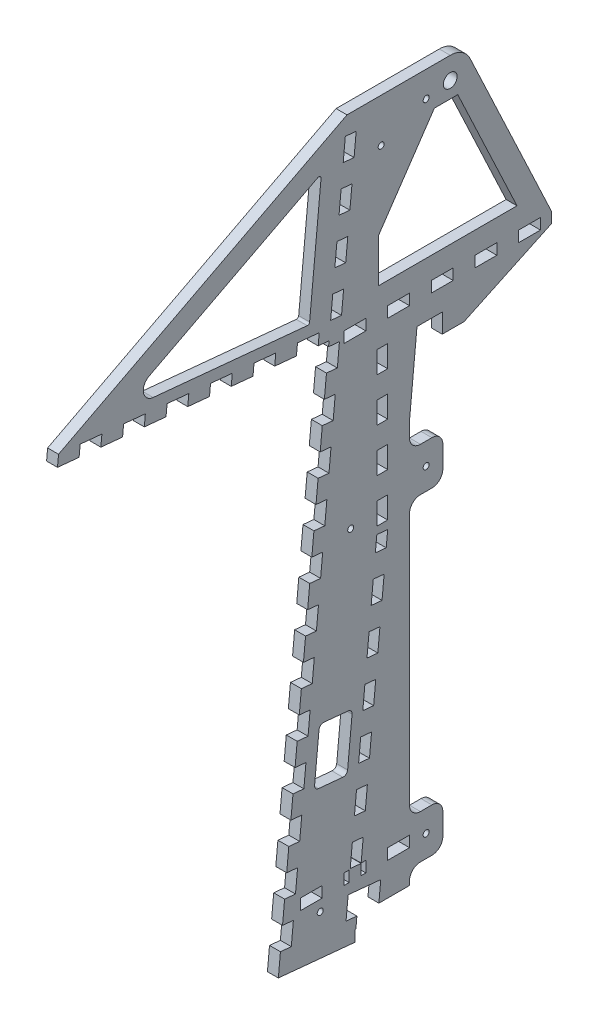
from build123d import *

# Parameters (mm, degrees)
BOSS_EXTRUDE1_DEPTH = 6.35
SKETCH2_W           = 19.05
SKETCH2_H           = 84.666666666
SKETCH2_H_2         = 84.666666667
CUT_EXTRUDE4_DEPTH  = 7.35
FILLET1_R           = 12.7
SKETCH3_R           = 4
CUT_EXTRUDE5_DEPTH  = 7.35
FILLET2_R           = 6.35
CUT_EXTRUDE6_DEPTH  = 7.35
CUT_EXTRUDE11_DEPTH = 7.35
LPATTERN1_COUNT     = 17
LPATTERN1_PITCH     = 25.4
CUT_EXTRUDE13_DEPTH = 7.35
LPATTERN2_COUNT     = 17
LPATTERN2_PITCH     = 25.4
SKETCH8_W           = 12.7
SKETCH8_H           = 6.35
CUT_EXTRUDE14_DEPTH = 7.35
LPATTERN3_COUNT     = 5
LPATTERN3_PITCH     = 25.4
SKETCH9_W           = 12.7
SKETCH9_H           = 6.35
CUT_EXTRUDE15_DEPTH = 7.35
LPATTERN4_COUNT     = 3
LPATTERN4_PITCH     = 25.4
CUT_EXTRUDE16_DEPTH = 7.35
LPATTERN5_COUNT     = 8
LPATTERN5_PITCH     = 25.4
BOSS_EXTRUDE2_DEPTH = 6.35
SKETCH13_W          = 12.7
SKETCH13_H          = 6.35
CUT_EXTRUDE17_DEPTH = 7.35
LPATTERN6_COUNT     = 3
LPATTERN6_PITCH     = 25.4
SKETCH15_W          = 2.976007875
SKETCH15_H          = 6.35
CUT_EXTRUDE20_DEPTH = 7.35
CUT_EXTRUDE21_DEPTH = 7.35
SKETCH17_W          = 6.35
SKETCH17_H          = 6.35
CUT_EXTRUDE22_DEPTH = 7.35
SKETCH18_W          = 6.35
SKETCH18_H          = 12.7
CUT_EXTRUDE23_DEPTH = 7.35
LPATTERN7_COUNT     = 4
LPATTERN7_PITCH     = 25.4
SKETCH19_R          = 1.75
CUT_EXTRUDE24_DEPTH = 7.35
SKETCH20_W          = 6.35
SKETCH20_H          = 6.35
BOSS_EXTRUDE3_DEPTH = 6.35
FILLET3_R           = 2.54
FILLET4_R           = 1.27
CUT_EXTRUDE27_DEPTH = 7.35
CUT_EXTRUDE28_DEPTH = 7.35
SKETCH23_W          = 50.8
SKETCH23_H          = 12.7
CUT_EXTRUDE29_DEPTH = 7.35
CUT_EXTRUDE30_DEPTH = 7.35
SKETCH25_R          = 1.75
CUT_EXTRUDE32_DEPTH = 7.35
SKETCH26_W          = 19.381019212
SKETCH26_H          = 25.4
SKETCH26_R          = 1.75
BOSS_EXTRUDE4_DEPTH = 6.35
FILLET5_R           = 6.35


with BuildPart() as part:
    # Sketch1 → Boss-Extrude1 (new body)
    with BuildSketch(Plane(origin=(0, 0, 0), x_dir=(0, 0, -1), z_dir=(1, 0, 0))):
        Polygon((-128.051747831, 325.716377135), (29.898471713, 310.507500832), (0.41022444, 4.2603437), (44.655585457, 0), (108.458541785, 0), (108.458541785, 280.894117647), (159.258541785, 304.8), (159.258541785, 311.15), (108.458541785, 419.1), (40.3547401, 419.1), (-127.443127302, 332.037142994), align=None)
    extrude(amount=BOSS_EXTRUDE1_DEPTH)

    # Sketch2 → Cut-Extrude4 (cut, through all)
    with BuildSketch(Plane(origin=(6.35, 0, 0), x_dir=(0, 0, -1), z_dir=(1, 0, 0))):
        Polygon((-93.813479632, 335.17834558), (25.474926883, 397.071798933), (18.474181051, 324.366273609), align=None)
        Polygon((91.177408074, 397.071798933), (84.126950747, 323.85), (139.246110214, 323.85), (104.788793069, 397.071798933), align=None)
        Polygon((81.069773467, 292.1), (76.708541785, 246.806877223), (76.708541785, 207.433333333), (95.758541785, 207.433333333), (95.758541785, 292.1), align=None)
        with Locations((86.233541785, 152.4)):
            Rectangle(SKETCH2_W, SKETCH2_H)
        with Locations((86.233541785, 55.033333334)):
            Rectangle(SKETCH2_W, SKETCH2_H_2)
    extrude(amount=-CUT_EXTRUDE4_DEPTH, mode=Mode.SUBTRACT)

    # Fillet1
    fillet1_edges = [part.edges().sort_by_distance(p)[0] for p in [
        (3.175, 419.1, -108.458541785),
    ]]
    fillet(fillet1_edges, radius=FILLET1_R)

    # Sketch3 → Cut-Extrude5 (cut, through all)
    with BuildSketch(Plane(origin=(6.35, 0, 0), x_dir=(0, 0, -1), z_dir=(1, 0, 0))):
        with Locations((100.399051391, 406.4)):
            Circle(SKETCH3_R)
    extrude(amount=-CUT_EXTRUDE5_DEPTH, mode=Mode.SUBTRACT)

    # Fillet2
    fillet2_edges = [part.edges().sort_by_distance(p)[0] for p in [
        (3.175, 335.17834558, 93.813479632),
    ]]
    fillet(fillet2_edges, radius=FILLET2_R)

    # Sketch4 → Cut-Extrude6 (cut, through all)
    with BuildSketch(Plane(origin=(6.35, 0, 0), x_dir=(0, 0, -1), z_dir=(1, 0, 0))):
        Polygon((21.256152575, 88.249017223), (24.323216655, 120.10169557), (43.534363284, 118.251872547), (40.467299203, 86.399194199), align=None)
    extrude(amount=-CUT_EXTRUDE6_DEPTH, mode=Mode.SUBTRACT)

    # Sketch5 → Cut-Extrude11 (cut, through all)
    with BuildSketch(Plane(origin=(6.35, 0, 0), x_dir=(0, 0, -1), z_dir=(1, 0, 0))):
        Polygon((1.627465497, 16.901875419), (2.844706554, 29.543407138), (9.165472413, 28.93478661), (7.948231356, 16.29325489), align=None)
    cut_extrude11 = extrude(amount=-CUT_EXTRUDE11_DEPTH, mode=Mode.SUBTRACT)

    # LPattern1: Cut-Extrude11 ×17
    with Locations(*[Vector(0, 0.995396198, -0.095845753) * (i * LPATTERN1_PITCH) for i in range(1, LPATTERN1_COUNT)]):
        add(cut_extrude11, mode=Mode.SUBTRACT)

    # Sketch7 → Cut-Extrude13 (cut, through all)
    with BuildSketch(Plane(origin=(6.35, 0, 0), x_dir=(0, 0, -1), z_dir=(1, 0, 0))):
        Polygon((23.577705854, 311.116121361), (10.936174134, 312.333362418), (11.544794663, 318.654128277), (24.186326382, 317.43688722), align=None)
    cut_extrude13 = extrude(amount=-CUT_EXTRUDE13_DEPTH, mode=Mode.SUBTRACT)

    # LPattern2: Cut-Extrude13 ×17
    with Locations(*[Vector(0, 0.095845753, 0.995396198) * (i * LPATTERN2_PITCH) for i in range(1, LPATTERN2_COUNT)]):
        add(cut_extrude13, mode=Mode.SUBTRACT)

    # Sketch8 → Cut-Extrude14 (cut, through all)
    with BuildSketch(Plane(origin=(6.35, 0, 0), x_dir=(0, 0, -1), z_dir=(1, 0, 0))):
        with Locations((146.558541785, 307.975)):
            Rectangle(SKETCH8_W, SKETCH8_H)
    cut_extrude14 = extrude(amount=-CUT_EXTRUDE14_DEPTH, mode=Mode.SUBTRACT)

    # LPattern3: Cut-Extrude14 ×5
    with Locations(*[(0, 0, i * LPATTERN3_PITCH) for i in range(1, LPATTERN3_COUNT)]):
        add(cut_extrude14, mode=Mode.SUBTRACT)

    # Sketch9 → Cut-Extrude15 (cut, through all)
    with BuildSketch(Plane(origin=(6.35, 0, 0), x_dir=(0, 0, -1), z_dir=(1, 0, 0))):
        with Locations((102.108541785, 3.175)):
            Rectangle(SKETCH9_W, SKETCH9_H)
    cut_extrude15 = extrude(amount=-CUT_EXTRUDE15_DEPTH, mode=Mode.SUBTRACT)

    # LPattern4: Cut-Extrude15 ×3
    with Locations(*[(0, 0, i * LPATTERN4_PITCH) for i in range(1, LPATTERN4_COUNT)]):
        add(cut_extrude15, mode=Mode.SUBTRACT)

    # Sketch11 → Cut-Extrude16 (cut, through all)
    with BuildSketch(Plane(origin=(6.35, 0, 0), x_dir=(0, 0, -1), z_dir=(1, 0, 0))):
        Polygon((39.800909704, 13.22619081), (46.121675564, 12.617570281), (47.338916621, 25.259102), (41.018150761, 25.867722529), align=None)
    cut_extrude16 = extrude(amount=-CUT_EXTRUDE16_DEPTH, mode=Mode.SUBTRACT)

    # LPattern5: Cut-Extrude16 ×8
    with Locations(*[Vector(0, 0.995396198, -0.095845753) * (i * LPATTERN5_PITCH) for i in range(1, LPATTERN5_COUNT)]):
        add(cut_extrude16, mode=Mode.SUBTRACT)

    # Sketch12 → Boss-Extrude2 (add, through all)
    with BuildSketch(Plane(origin=(6.35, 0, 0), x_dir=(0, 0, -1), z_dir=(1, 0, 0))):
        Polygon((58.059525559, 202.849166599), (64.380291419, 202.24054607), (64.008541785, 198.379778502), (57.687775925, 198.988399031), align=None)
    extrude(amount=-BOSS_EXTRUDE2_DEPTH)

    # Sketch13 → Cut-Extrude17 (cut, through all)
    with BuildSketch(Plane(origin=(6.35, 0, 0), x_dir=(0, 0, -1), z_dir=(1, 0, 0))):
        with Locations((70.358541785, 34.925)):
            Rectangle(SKETCH13_W, SKETCH13_H)
    cut_extrude17 = extrude(amount=-CUT_EXTRUDE17_DEPTH, mode=Mode.SUBTRACT)

    # LPattern6: Cut-Extrude17 ×3, 1 skipped
    with Locations(*[(0, 0, i * LPATTERN6_PITCH) for i in range(1, LPATTERN6_COUNT) if i not in (1,)]):
        add(cut_extrude17, mode=Mode.SUBTRACT)

    # Sketch15 → Cut-Extrude20 (cut, through all)
    with BuildSketch(Plane(origin=(6.35, 0, 0), x_dir=(0, 0, -1), z_dir=(1, 0, 0))):
        with Locations((40.096545722, 34.925)):
            Rectangle(SKETCH15_W, SKETCH15_H)
        Polygon((48.575354467, 31.75), (51.308541785, 31.75), (51.308541785, 38.1), (48.575354467, 38.1), (48.556157678, 37.90063372), (48.575354467, 37.90063372), align=None)
    extrude(amount=-CUT_EXTRUDE20_DEPTH, mode=Mode.SUBTRACT)

    # Sketch16 → Cut-Extrude21 (cut, through all)
    with BuildSketch(Plane(origin=(6.35, 0, 0), x_dir=(0, 0, -1), z_dir=(1, 0, 0))):
        Polygon((47.338916621, 25.259102), (45.518177187, 6.35), (58.276915889, 6.35), (59.98044834, 24.041860943), align=None)
    extrude(amount=-CUT_EXTRUDE21_DEPTH, mode=Mode.SUBTRACT)

    # Sketch17 → Cut-Extrude22 (cut, through all)
    with BuildSketch(Plane(origin=(6.35, 0, 0), x_dir=(0, 0, -1), z_dir=(1, 0, 0))):
        with Locations((60.833541785, 307.975)):
            Rectangle(SKETCH17_W, SKETCH17_H)
    extrude(amount=-CUT_EXTRUDE22_DEPTH, mode=Mode.SUBTRACT)

    # Sketch18 → Cut-Extrude23 (cut, through all)
    with BuildSketch(Plane(origin=(6.35, 0, 0), x_dir=(0, 0, -1), z_dir=(1, 0, 0))):
        with Locations((60.833541785, 285.75)):
            Rectangle(SKETCH18_W, SKETCH18_H)
    cut_extrude23 = extrude(amount=-CUT_EXTRUDE23_DEPTH, mode=Mode.SUBTRACT)

    # LPattern7: Cut-Extrude23 ×4
    with Locations(*[(0, -i * LPATTERN7_PITCH, 0) for i in range(1, LPATTERN7_COUNT)]):
        add(cut_extrude23, mode=Mode.SUBTRACT)

    # Sketch19 → Cut-Extrude24 (cut, through all)
    with BuildSketch(Plane(origin=(6.35, 0, 0), x_dir=(0, 0, -1), z_dir=(1, 0, 0))):
        with Locations((42.505326788, 209.551703302)):
            Circle(SKETCH19_R)
        with Locations((60.236791004, 393.7)):
            Circle(SKETCH19_R)
        with Locations((24.773862572, 25.403406604)):
            Circle(SKETCH19_R)
    extrude(amount=-CUT_EXTRUDE24_DEPTH, mode=Mode.SUBTRACT)

    # Sketch20 → Boss-Extrude3 (add, through all)
    with BuildSketch(Plane(origin=(6.35, 0, 0), x_dir=(0, 0, -1), z_dir=(1, 0, 0))):
        with Locations((60.833541785, 307.975)):
            Rectangle(SKETCH20_W, SKETCH20_H)
    extrude(amount=-BOSS_EXTRUDE3_DEPTH)

    # Fillet3
    fillet3_edges = [part.edges().sort_by_distance(p)[0] for p in [
        (3.175, 86.399194199, -40.467299203),
        (3.175, 88.249017223, -21.256152575),
        (3.175, 120.10169557, -24.323216655),
        (3.175, 118.251872547, -43.534363284),
    ]]
    fillet(fillet3_edges, radius=FILLET3_R)

    # Fillet4
    fillet4_edges = [part.edges().sort_by_distance(p)[0] for p in [
        (3.175, 324.366273609, -18.474181051),
        (3.175, 397.071798933, -25.474926883),
    ]]
    fillet(fillet4_edges, radius=FILLET4_R)

    # Sketch21 → Cut-Extrude27 (cut, through all)
    with BuildSketch(Plane(origin=(6.35, 0, 0), x_dir=(0, 0, -1), z_dir=(1, 0, 0))):
        Polygon((84.126950747, 323.85), (58.726950747, 323.85), (58.726950747, 349.25), (86.572692571, 349.25), align=None)
    extrude(amount=-CUT_EXTRUDE27_DEPTH, mode=Mode.SUBTRACT)

    # Sketch22 → Cut-Extrude28 (cut, through all)
    with BuildSketch(Plane(origin=(6.35, 0, 0), x_dir=(0, 0, -1), z_dir=(1, 0, 0))):
        Polygon((58.726950747, 349.25), (91.177408074, 397.071798933), (86.572692571, 349.25), align=None)
    extrude(amount=-CUT_EXTRUDE28_DEPTH, mode=Mode.SUBTRACT)

    # Sketch23 → Cut-Extrude29 (cut, through all)
    with BuildSketch(Plane(origin=(6.35, 0, 0), x_dir=(0, 0, -1), z_dir=(1, 0, 0))):
        with Locations((83.058541785, 6.35)):
            Rectangle(SKETCH23_W, SKETCH23_H)
    extrude(amount=-CUT_EXTRUDE29_DEPTH, mode=Mode.SUBTRACT)

    # Sketch24 → Cut-Extrude30 (cut, through all)
    with BuildSketch(Plane(origin=(6.35, 0, 0), x_dir=(0, 0, -1), z_dir=(1, 0, 0))):
        Polygon((76.708541785, 12.7), (76.708541785, 207.433333333), (95.758541785, 280.894117647), (108.458541785, 280.894117647), (108.458541785, 12.7), align=None)
    extrude(amount=-CUT_EXTRUDE30_DEPTH, mode=Mode.SUBTRACT)

    # Sketch25 → Cut-Extrude32 (cut, through all)
    with BuildSketch(Plane(origin=(6.35, 0, 0), x_dir=(0, 0, -1), z_dir=(1, 0, 0))):
        with Locations((86.399051391, 404.1)):
            Circle(SKETCH25_R)
    extrude(amount=-CUT_EXTRUDE32_DEPTH, mode=Mode.SUBTRACT)

    # Sketch26 → Boss-Extrude4 (add)
    with BuildSketch(Plane.ZY):
        with Locations((-86.399051391, 219.1)):
            Rectangle(SKETCH26_W, SKETCH26_H)
        with Locations((-86.399051391, 219.1)):
            Circle(SKETCH26_R, mode=Mode.SUBTRACT)
        with Locations((-86.399051391, 34.1)):
            Rectangle(SKETCH26_W, SKETCH26_H)
        with Locations((-86.399051391, 34.1)):
            Circle(SKETCH26_R, mode=Mode.SUBTRACT)
    extrude(amount=-BOSS_EXTRUDE4_DEPTH)

    # Fillet5
    fillet5_edges = [part.edges().sort_by_distance(p)[0] for p in [
        (3.175, 231.8, -76.708541785),
        (3.175, 206.4, -76.708541785),
        (3.175, 206.4, -96.089560997),
        (3.175, 231.8, -96.089560997),
        (3.175, 46.8, -76.708541785),
        (3.175, 21.4, -76.708541785),
        (3.175, 21.4, -96.089560997),
        (3.175, 46.8, -96.089560997),
    ]]
    fillet(fillet5_edges, radius=FILLET5_R)


solid = part.part
